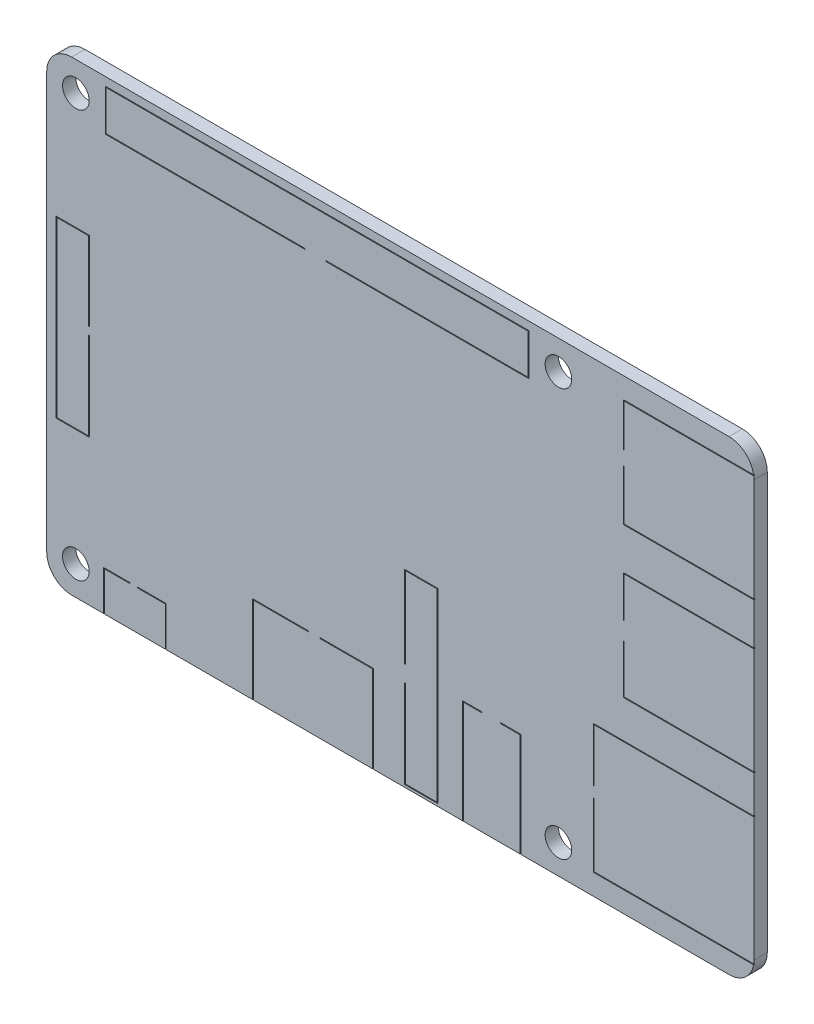
from build123d import *

# Parameters (mm, degrees)
SKETCH1_R           = 1.6
BOSS_EXTRUDE1_DEPTH = 1.6
CUT_EXTRUDE1_DEPTH  = 0.1


with BuildPart() as part:
    # Sketch1 → Boss-Extrude1 (new body)
    with BuildSketch(Plane.XY):
        with BuildLine():
            Line((-39.5, -28), (39.5, -28))
            ThreePointArc((39.5, -28), (41.621320344, -27.121320344), (42.5, -25))
            Line((42.5, -25), (42.5, 25))
            ThreePointArc((42.5, 25), (41.621320344, 27.121320344), (39.5, 28))
            Line((39.5, 28), (-39.5, 28))
            ThreePointArc((-39.5, 28), (-41.621320344, 27.121320344), (-42.5, 25))
            Line((-42.5, 25), (-42.5, -25))
            ThreePointArc((-42.5, -25), (-41.621320344, -27.121320344), (-39.5, -28))
        make_face()
        with Locations((-39, 24.5)):
            Circle(SKETCH1_R, mode=Mode.SUBTRACT)
        with Locations((-39, -24.5)):
            Circle(SKETCH1_R, mode=Mode.SUBTRACT)
        with Locations((19, 24.5)):
            Circle(SKETCH1_R, mode=Mode.SUBTRACT)
        with Locations((19, -24.5)):
            Circle(SKETCH1_R, mode=Mode.SUBTRACT)
    extrude(amount=BOSS_EXTRUDE1_DEPTH)

    # Sketch2 → Cut-Extrude1 (cut)
    with BuildSketch(Plane.XY.offset(1.6)):
        Polygon((-35.65, -28.636850855), (-28.15, -28.636850855), (-28.15, -23.2), (-31.573707352, -23.2), (-31.573707352, -23.3), (-28.25, -23.3), (-28.25, -28.536850855), (-35.55, -28.536850855), (-35.55, -23.3), (-32.465045999, -23.3), (-32.465045999, -23.2), (-35.65, -23.2), align=None)
        Polygon((-17.75, -17.5), (-11.015830732, -17.5), (-11.015830732, -17.6), (-17.65, -17.6), (-17.65, -33.061376344), (-3.35, -33.061376344), (-3.35, -17.6), (-9.684859924, -17.6), (-9.684859924, -17.5), (-3.25, -17.5), (-3.25, -33.161376344), (-17.75, -33.161376344), align=None)
        Polygon((0.5, -5.3), (4.5, -5.3), (4.5, -27.7), (0.5, -27.7), (0.5, -17.125), (0.6, -17.125), (0.6, -27.6), (4.4, -27.6), (4.4, -5.4), (0.6, -5.4), (0.6, -15.17398131), (0.5, -15.17398131), align=None)
        Polygon((7.5, -15.5), (9.799158316, -15.5), (9.799158316, -15.6), (7.6, -15.6), (7.6, -31.061376344), (14.4, -31.061376344), (14.4, -15.6), (12.062610562, -15.6), (12.062610562, -15.5), (14.5, -15.5), (14.5, -31.161376344), (7.5, -31.161376344), align=None)
        Polygon((-35.45, 27), (15.45, 27), (15.45, 22), (-8.906687942, 22), (-8.906687942, 22.1), (15.35, 22.1), (15.35, 26.9), (-35.35, 26.9), (-35.35, 22.1), (-11.458179647, 22.1), (-11.458179647, 22), (-35.45, 22), align=None)
        Polygon((-41.371710411, -10.514157593), (-37.371710411, -10.514157593), (-37.371710411, 0.094714316), (-37.471710411, 0.094714316), (-37.471710411, -10.414157593), (-41.271710411, -10.414157593), (-41.271710411, 10.414157593), (-37.471710411, 10.414157593), (-37.471710411, 1), (-37.371710411, 1), (-37.371710411, 10.514157593), (-41.371710411, 10.514157593), align=None)
        Polygon((23.2, -25.5), (44.7, -25.5), (44.7, -10), (23.2, -10), (23.2, -16.5), (23.3, -16.5), (23.3, -10.1), (44.6, -10.1), (44.6, -25.4), (23.3, -25.4), (23.3, -17.75), (23.2, -17.75), align=None)
        Polygon((26.8, -5.5), (54.071370237, -5.5), (54.071370237, 7.5), (26.8, 7.5), (26.8, 2.552788505), (26.9, 2.552788505), (26.9, 7.4), (53.971370237, 7.4), (53.971370237, -5.4), (26.9, -5.4), (26.9, 0.407211154), (26.8, 0.407211154), align=None)
        Polygon((26.8, 12.5), (57.71374017, 12.5), (57.71374017, 25.5), (26.8, 25.5), (26.8, 20.277341759), (26.9, 20.277341759), (26.9, 25.4), (57.61374017, 25.4), (57.61374017, 12.6), (26.9, 12.6), (26.9, 18.611308355), (26.8, 18.611308355), align=None)
    extrude(amount=-CUT_EXTRUDE1_DEPTH, mode=Mode.SUBTRACT)


solid = part.part
